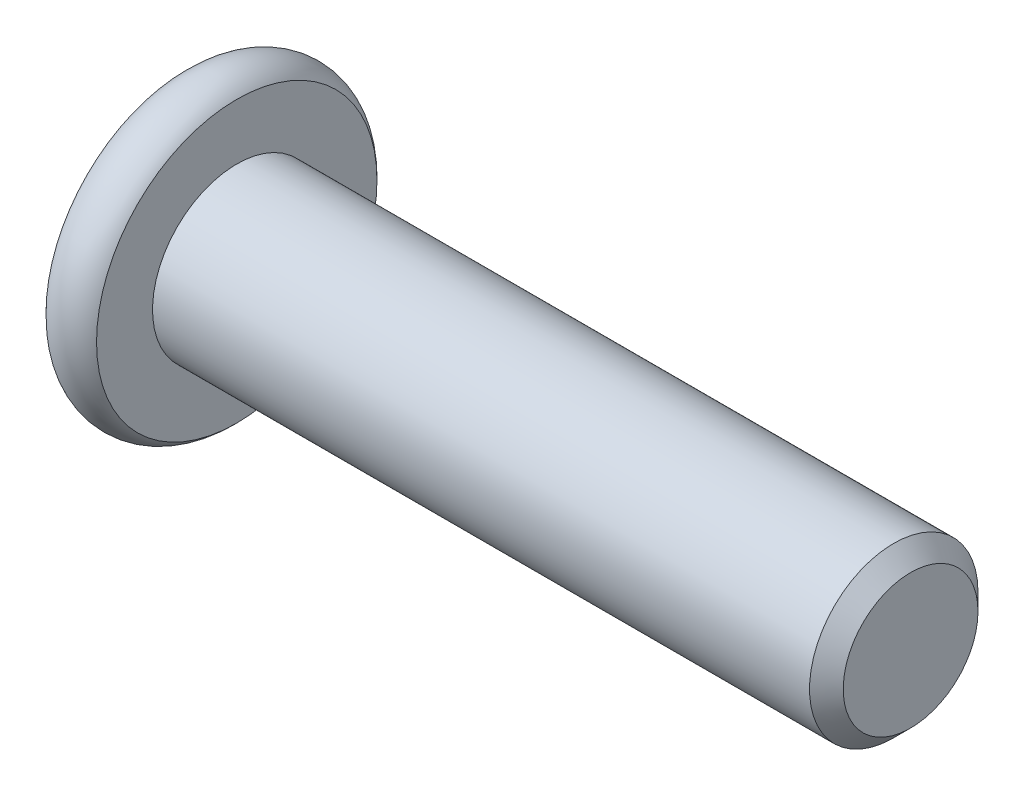
from build123d import *

# Parameters (mm, degrees)
SKETCH2_R           = 2.5
BOSS_EXTRUDE1_DEPTH = 20
CHAMFER1_SIZE       = 0.5
CUT_EXTRUDE1_DEPTH  = 2.3
SKETCH8_R           = 1.782050808
CUT_EXTRUDE2_DEPTH  = 1
CUT_EXTRUDE2_TAPER  = 45


with BuildPart() as part:
    # Sketch2 → Boss-Extrude1 (new body)
    with BuildSketch(Plane(origin=(0, 0, 0), x_dir=(0, 0, -1), z_dir=(1, 0, 0))):
        Circle(SKETCH2_R)
    extrude(amount=-BOSS_EXTRUDE1_DEPTH)

    # Chamfer1
    chamfer1_edges = [part.edges().sort_by_distance(p)[0] for p in [
        (0, 0, 2.5),
    ]]
    chamfer(chamfer1_edges, length=CHAMFER1_SIZE)

    # Sketch6 → Revolve1 (revolve)
    with BuildSketch(Plane.XY):
        with BuildLine():
            Line((-21.5, 0), (-21.5, 4.161437828))
            ThreePointArc((-21.5, 4.161437828), (-20.75, 4.5), (-20, 4.161437828))
            Line((-20, 4.161437828), (-20, 0))
            Line((-20, 0), (-21.5, 0))
        make_face()
    revolve(axis=Axis((-20, 0, 0), (1, 0, 0)))

    # Sketch7 → Cut-Extrude1 (cut)
    with BuildSketch(Plane.ZY.offset(21.5)):
        Polygon((0, 1.732050808), (-1.5, 0.866025404), (-1.5, -0.866025404), (0, -1.732050808), (1.5, -0.866025404), (1.5, 0.866025404), align=None)
    extrude(amount=-CUT_EXTRUDE1_DEPTH, mode=Mode.SUBTRACT)

    # Sketch8 → Cut-Extrude2 (cut)
    with BuildSketch(Plane.ZY.offset(21.5)):
        Circle(SKETCH8_R)
    extrude(amount=-CUT_EXTRUDE2_DEPTH, taper=CUT_EXTRUDE2_TAPER, mode=Mode.SUBTRACT)


solid = part.part
